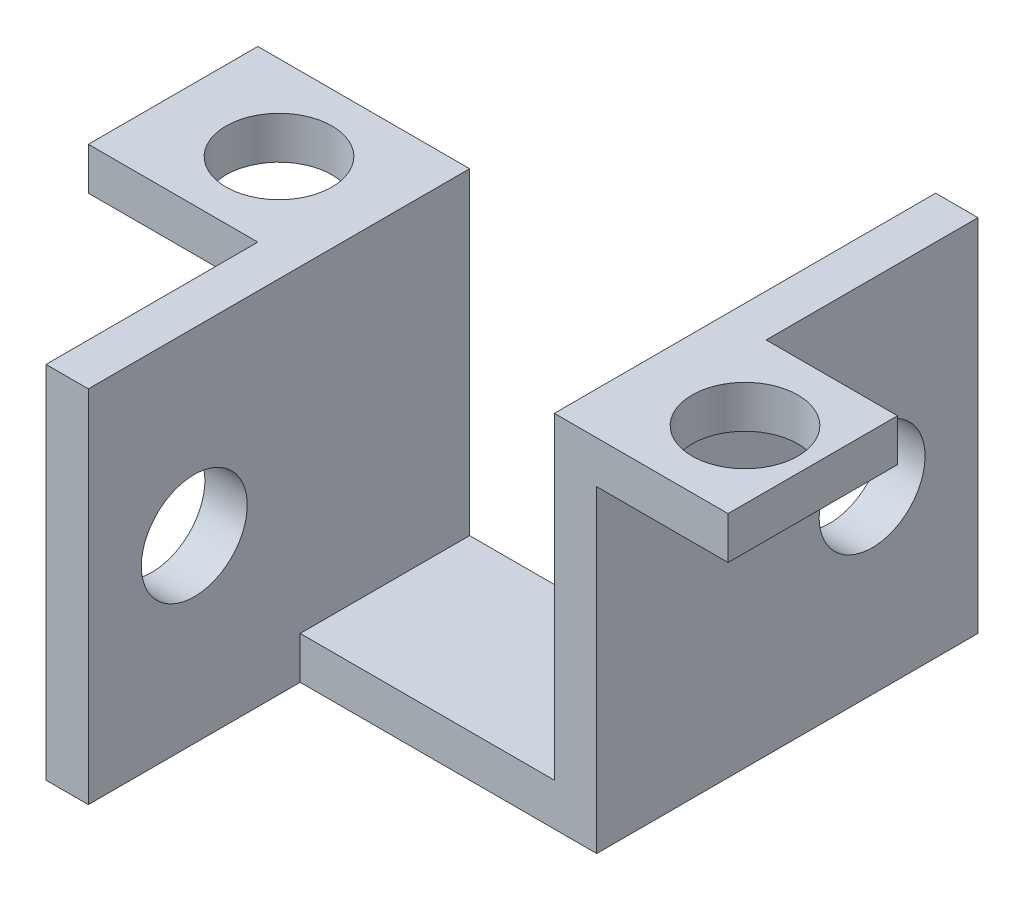
from build123d import *

# Parameters (mm, degrees)
CROQUIS1_W              = 8
CROQUIS1_H              = 2
SALIENTE_EXTRUIR1_DEPTH = 8
CROQUIS2_R              = 2.5
CORTAR_EXTRUIR1_DEPTH   = 2
SKETCH1_W               = 8
SKETCH1_H               = 2
CUT_EXTRUDE1_DEPTH      = 1.8
SKETCH5_W               = 10
SKETCH5_H               = 17
BOSS_EXTRUDE3_DEPTH     = 2
SKETCH6_W               = 10
SKETCH6_H               = 17
SKETCH6_R               = 2.5
BOSS_EXTRUDE4_DEPTH     = 2
SKETCH7_R               = 2.5
CUT_EXTRUDE2_DEPTH      = 2


with BuildPart() as part:
    # Croquis1 → Saliente-Extruir1 (new body)
    with BuildSketch(Plane.XY):
        with Locations((-12, 6.5)):
            Rectangle(CROQUIS1_W, CROQUIS1_H)
        Polygon((-6, 7.5), (-8, 7.5), (-8, 5.5), (-8, -9.5), (8, -9.5), (8, 5.5), (8, 7.5), (6, 7.5), (6, -7.5), (-6, -7.5), align=None)
        with Locations((12, 6.5)):
            Rectangle(CROQUIS1_W, CROQUIS1_H)
    extrude(amount=SALIENTE_EXTRUIR1_DEPTH)

    # Croquis2 → Cortar-Extruir1 (cut)
    with BuildSketch(Plane(origin=(0, 7.5, 0), x_dir=(1, 0, 0), z_dir=(0, 1, 0))):
        with Locations((-11, -4)):
            Circle(CROQUIS2_R)
        with Locations((11, -4)):
            Circle(CROQUIS2_R)
    extrude(amount=-CORTAR_EXTRUIR1_DEPTH, mode=Mode.SUBTRACT)

    # Sketch1 → Cut-Extrude1 (cut)
    with BuildSketch(Plane(origin=(16, 0, 0), x_dir=(0, 0, -1), z_dir=(1, 0, 0))):
        with Locations((-4, 6.5)):
            Rectangle(SKETCH1_W, SKETCH1_H)
    extrude(amount=-CUT_EXTRUDE1_DEPTH, mode=Mode.SUBTRACT)

    # Sketch5 → Boss-Extrude3 (add)
    with BuildSketch(Plane.ZY.offset(8)):
        with Locations((13, -1)):
            Rectangle(SKETCH5_W, SKETCH5_H)
    extrude(amount=-BOSS_EXTRUDE3_DEPTH)

    # Sketch6 → Boss-Extrude4 (add)
    with BuildSketch(Plane(origin=(8, 0, 0), x_dir=(0, 0, -1), z_dir=(1, 0, 0))):
        with Locations((5, -1)):
            Rectangle(SKETCH6_W, SKETCH6_H)
        with Locations((5, -1)):
            Circle(SKETCH6_R, mode=Mode.SUBTRACT)
    extrude(amount=-BOSS_EXTRUDE4_DEPTH)

    # Sketch7 → Cut-Extrude2 (cut)
    with BuildSketch(Plane.ZY.offset(8)):
        with Locations((13, -1)):
            Circle(SKETCH7_R)
    extrude(amount=-CUT_EXTRUDE2_DEPTH, mode=Mode.SUBTRACT)


solid = part.part
